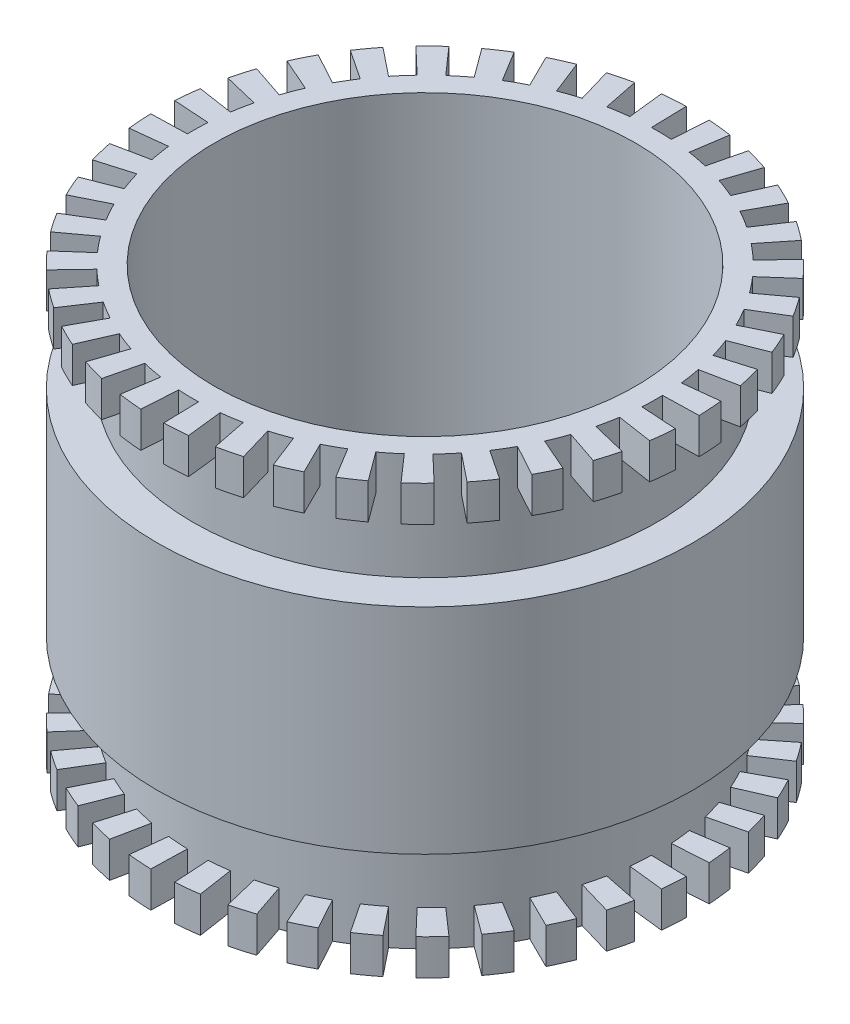
from build123d import *

# Parameters (mm, degrees)
SKETCH1_R           = 37.5
SKETCH1_R_2         = 29.5
BOSS_EXTRUDE1_DEPTH = 60
CUT_EXTRUDE1_DEPTH  = 5
SKETCH3_R           = 37.5
SKETCH3_R_2         = 32.5
CUT_EXTRUDE2_DEPTH  = 10
CUT_EXTRUDE3_DEPTH  = 5
SKETCH5_R           = 37.5
SKETCH5_R_2         = 32.5
CUT_EXTRUDE4_DEPTH  = 10


with BuildPart() as part:
    # Sketch1 → Boss-Extrude1 (new body)
    with BuildSketch(Plane(origin=(0, 0, 0), x_dir=(1, 0, 0), z_dir=(0, 1, 0))):
        Circle(SKETCH1_R)
        Circle(SKETCH1_R_2, mode=Mode.SUBTRACT)
    extrude(amount=BOSS_EXTRUDE1_DEPTH)

    # Sketch2 → Cut-Extrude1 (cut)
    with BuildSketch(Plane.XZ):
        with BuildLine():
            Line((-0.781337231, 32.490606521), (-0.901542959, 37.489161371))
            ThreePointArc((-0.901542959, 37.489161371), (0.734569362, 37.492804748), (2.369283389, 37.42507844))
            Line((2.369283389, 37.42507844), (2.053378937, 32.435067981))
            ThreePointArc((2.053378937, 32.435067981), (0.636626781, 32.493764115), (-0.781337231, 32.490606521))
        make_face()
        with BuildLine():
            Line((4.872467651, 32.132678989), (5.622078059, 37.076168064))
            ThreePointArc((5.622078059, 37.076168064), (7.233966823, 36.795648167), (8.83208532, 36.445085662))
            Line((8.83208532, 36.445085662), (7.654473944, 31.585740907))
            ThreePointArc((7.654473944, 31.585740907), (6.269437913, 31.889561744), (4.872467651, 32.132678989))
        make_face()
        with BuildLine():
            Line((10.378225069, 30.798416265), (11.97487508, 35.536634152))
            ThreePointArc((11.97487508, 35.536634152), (13.513563863, 34.980474435), (15.026528809, 34.357727398))
            Line((15.026528809, 34.357727398), (13.022991634, 29.776697078))
            ThreePointArc((13.022991634, 29.776697078), (11.711755348, 30.316411177), (10.378225069, 30.798416265))
        make_face()
        with BuildLine():
            Line((15.56864537, 28.528359247), (17.963821581, 32.917337593))
            ThreePointArc((17.963821581, 32.917337593), (19.382558102, 32.10243669), (20.764398823, 31.226426973))
            Line((20.764398823, 31.226426973), (17.995812313, 27.062903377))
            ThreePointArc((17.995812313, 27.062903377), (16.798217022, 27.822111798), (15.56864537, 28.528359247))
        make_face()
        with BuildLine():
            Line((20.286020259, 25.39148247), (23.406946453, 29.297864389))
            ThreePointArc((23.406946453, 29.297864389), (24.662623122, 28.24898265), (25.871353087, 27.146327366))
            Line((25.871353087, 27.146327366), (22.421839342, 23.526817051))
            ThreePointArc((22.421839342, 23.526817051), (21.374273373, 24.48245163), (20.286020259, 25.39148247))
        make_face()
        with BuildLine():
            Line((24.387014688, 21.483098347), (28.138863102, 24.788190401))
            ThreePointArc((28.138863102, 24.788190401), (29.193326818, 23.537197566), (30.192219378, 22.241400339))
            Line((30.192219378, 22.241400339), (26.166590128, 19.275880293))
            ThreePointArc((26.166590128, 19.275880293), (25.300883243, 20.398904557), (24.387014688, 21.483098347))
        make_face()
        with BuildLine():
            Line((27.747022016, 16.921961152), (32.015794634, 19.52533979))
            ThreePointArc((32.015794634, 19.52533979), (32.837006052, 18.110246645), (33.595710362, 16.660679617))
            Line((33.595710362, 16.660679617), (29.116282314, 14.439255668))
            ThreePointArc((29.116282314, 14.439255668), (28.458738578, 15.695547093), (27.747022016, 16.921961152))
        make_face()
        with BuildLine():
            Line((30.263950121, 11.846658729), (34.919942448, 13.669221611))
            ThreePointArc((34.919942448, 13.669221611), (35.482949473, 12.133025044), (35.978412686, 10.573732575))
            Line((35.978412686, 10.573732575), (31.181290995, 9.163901565))
            ThreePointArc((31.181290995, 9.163901565), (30.751889543, 10.515288372), (30.263950121, 11.846658729))
        make_face()
        with BuildLine():
            Line((31.861323416, 6.411401577), (36.76306548, 7.39777105))
            ThreePointArc((36.76306548, 7.39777105), (37.050761429, 5.787147617), (37.267929147, 4.16550802))
            Line((37.267929147, 4.16550802), (32.298871928, 3.610106951))
            ThreePointArc((32.298871928, 3.610106951), (32.110659905, 5.015527935), (31.861323416, 6.411401577))
        make_face()
        with BuildLine():
            Line((32.490606521, 0.781337231), (37.489161371, 0.901542959))
            ThreePointArc((37.489161371, 0.901542959), (37.492804748, -0.734569362), (37.42507844, -2.369283389))
            Line((37.42507844, -2.369283389), (32.435067981, -2.053378937))
            ThreePointArc((32.435067981, -2.053378937), (32.493764115, -0.636626781), (32.490606521, 0.781337231))
        make_face()
        with BuildLine():
            Line((32.132678989, -4.872467651), (37.076168064, -5.622078059))
            ThreePointArc((37.076168064, -5.622078059), (36.795648167, -7.233966823), (36.445085662, -8.83208532))
            Line((36.445085662, -8.83208532), (31.585740907, -7.654473944))
            ThreePointArc((31.585740907, -7.654473944), (31.889561744, -6.269437913), (32.132678989, -4.872467651))
        make_face()
        with BuildLine():
            Line((30.798416265, -10.378225069), (35.536634152, -11.97487508))
            ThreePointArc((35.536634152, -11.97487508), (34.980474435, -13.513563863), (34.357727398, -15.026528809))
            Line((34.357727398, -15.026528809), (29.776697078, -13.022991634))
            ThreePointArc((29.776697078, -13.022991634), (30.316411177, -11.711755348), (30.798416265, -10.378225069))
        make_face()
        with BuildLine():
            Line((28.528359247, -15.56864537), (32.917337593, -17.963821581))
            ThreePointArc((32.917337593, -17.963821581), (32.10243669, -19.382558102), (31.226426973, -20.764398823))
            Line((31.226426973, -20.764398823), (27.062903377, -17.995812313))
            ThreePointArc((27.062903377, -17.995812313), (27.822111798, -16.798217022), (28.528359247, -15.56864537))
        make_face()
        with BuildLine():
            Line((25.39148247, -20.286020259), (29.297864389, -23.406946453))
            ThreePointArc((29.297864389, -23.406946453), (28.24898265, -24.662623122), (27.146327366, -25.871353087))
            Line((27.146327366, -25.871353087), (23.526817051, -22.421839342))
            ThreePointArc((23.526817051, -22.421839342), (24.48245163, -21.374273373), (25.39148247, -20.286020259))
        make_face()
        with BuildLine():
            Line((21.483098347, -24.387014688), (24.788190401, -28.138863102))
            ThreePointArc((24.788190401, -28.138863102), (23.537197566, -29.193326818), (22.241400339, -30.192219378))
            Line((22.241400339, -30.192219378), (19.275880293, -26.166590128))
            ThreePointArc((19.275880293, -26.166590128), (20.398904557, -25.300883243), (21.483098347, -24.387014688))
        make_face()
        with BuildLine():
            Line((16.921961152, -27.747022016), (19.52533979, -32.015794634))
            ThreePointArc((19.52533979, -32.015794634), (18.110246645, -32.837006052), (16.660679617, -33.595710362))
            Line((16.660679617, -33.595710362), (14.439255668, -29.116282314))
            ThreePointArc((14.439255668, -29.116282314), (15.695547093, -28.458738578), (16.921961152, -27.747022016))
        make_face()
        with BuildLine():
            Line((11.846658729, -30.263950121), (13.669221611, -34.919942448))
            ThreePointArc((13.669221611, -34.919942448), (12.133025044, -35.482949473), (10.573732575, -35.978412686))
            Line((10.573732575, -35.978412686), (9.163901565, -31.181290995))
            ThreePointArc((9.163901565, -31.181290995), (10.515288372, -30.751889543), (11.846658729, -30.263950121))
        make_face()
        with BuildLine():
            Line((6.411401577, -31.861323416), (7.39777105, -36.76306548))
            ThreePointArc((7.39777105, -36.76306548), (5.787147617, -37.050761429), (4.16550802, -37.267929147))
            Line((4.16550802, -37.267929147), (3.610106951, -32.298871928))
            ThreePointArc((3.610106951, -32.298871928), (5.015527935, -32.110659905), (6.411401577, -31.861323416))
        make_face()
        with BuildLine():
            Line((0.781337231, -32.490606521), (0.901542959, -37.489161371))
            ThreePointArc((0.901542959, -37.489161371), (-0.734569362, -37.492804748), (-2.369283389, -37.42507844))
            Line((-2.369283389, -37.42507844), (-2.053378937, -32.435067981))
            ThreePointArc((-2.053378937, -32.435067981), (-0.636626781, -32.493764115), (0.781337231, -32.490606521))
        make_face()
        with BuildLine():
            Line((-4.872467651, -32.132678989), (-5.622078059, -37.076168064))
            ThreePointArc((-5.622078059, -37.076168064), (-7.233966823, -36.795648167), (-8.83208532, -36.445085662))
            Line((-8.83208532, -36.445085662), (-7.654473944, -31.585740907))
            ThreePointArc((-7.654473944, -31.585740907), (-6.269437913, -31.889561744), (-4.872467651, -32.132678989))
        make_face()
        with BuildLine():
            Line((-10.378225069, -30.798416265), (-11.97487508, -35.536634152))
            ThreePointArc((-11.97487508, -35.536634152), (-13.513563863, -34.980474435), (-15.026528809, -34.357727398))
            Line((-15.026528809, -34.357727398), (-13.022991634, -29.776697078))
            ThreePointArc((-13.022991634, -29.776697078), (-11.711755348, -30.316411177), (-10.378225069, -30.798416265))
        make_face()
        with BuildLine():
            Line((-15.56864537, -28.528359247), (-17.963821581, -32.917337593))
            ThreePointArc((-17.963821581, -32.917337593), (-19.382558102, -32.10243669), (-20.764398823, -31.226426973))
            Line((-20.764398823, -31.226426973), (-17.995812313, -27.062903377))
            ThreePointArc((-17.995812313, -27.062903377), (-16.798217022, -27.822111798), (-15.56864537, -28.528359247))
        make_face()
        with BuildLine():
            Line((-20.286020259, -25.39148247), (-23.406946453, -29.297864389))
            ThreePointArc((-23.406946453, -29.297864389), (-24.662623122, -28.24898265), (-25.871353087, -27.146327366))
            Line((-25.871353087, -27.146327366), (-22.421839342, -23.526817051))
            ThreePointArc((-22.421839342, -23.526817051), (-21.374273373, -24.48245163), (-20.286020259, -25.39148247))
        make_face()
        with BuildLine():
            Line((-24.387014688, -21.483098347), (-28.138863102, -24.788190401))
            ThreePointArc((-28.138863102, -24.788190401), (-29.193326818, -23.537197566), (-30.192219378, -22.241400339))
            Line((-30.192219378, -22.241400339), (-26.166590128, -19.275880293))
            ThreePointArc((-26.166590128, -19.275880293), (-25.300883243, -20.398904557), (-24.387014688, -21.483098347))
        make_face()
        with BuildLine():
            Line((-27.747022016, -16.921961152), (-32.015794634, -19.52533979))
            ThreePointArc((-32.015794634, -19.52533979), (-32.837006052, -18.110246645), (-33.595710362, -16.660679617))
            Line((-33.595710362, -16.660679617), (-29.116282314, -14.439255668))
            ThreePointArc((-29.116282314, -14.439255668), (-28.458738578, -15.695547093), (-27.747022016, -16.921961152))
        make_face()
        with BuildLine():
            Line((-30.263950121, -11.846658729), (-34.919942448, -13.669221611))
            ThreePointArc((-34.919942448, -13.669221611), (-35.482949473, -12.133025044), (-35.978412686, -10.573732575))
            Line((-35.978412686, -10.573732575), (-31.181290995, -9.163901565))
            ThreePointArc((-31.181290995, -9.163901565), (-30.751889543, -10.515288372), (-30.263950121, -11.846658729))
        make_face()
        with BuildLine():
            Line((-31.861323416, -6.411401577), (-36.76306548, -7.39777105))
            ThreePointArc((-36.76306548, -7.39777105), (-37.050761429, -5.787147617), (-37.267929147, -4.16550802))
            Line((-37.267929147, -4.16550802), (-32.298871928, -3.610106951))
            ThreePointArc((-32.298871928, -3.610106951), (-32.110659905, -5.015527935), (-31.861323416, -6.411401577))
        make_face()
        with BuildLine():
            Line((-32.490606521, -0.781337231), (-37.489161371, -0.901542959))
            ThreePointArc((-37.489161371, -0.901542959), (-37.492804748, 0.734569362), (-37.42507844, 2.369283389))
            Line((-37.42507844, 2.369283389), (-32.435067981, 2.053378937))
            ThreePointArc((-32.435067981, 2.053378937), (-32.493764115, 0.636626781), (-32.490606521, -0.781337231))
        make_face()
        with BuildLine():
            Line((-32.132678989, 4.872467651), (-37.076168064, 5.622078059))
            ThreePointArc((-37.076168064, 5.622078059), (-36.795648167, 7.233966823), (-36.445085662, 8.83208532))
            Line((-36.445085662, 8.83208532), (-31.585740907, 7.654473944))
            ThreePointArc((-31.585740907, 7.654473944), (-31.889561744, 6.269437913), (-32.132678989, 4.872467651))
        make_face()
        with BuildLine():
            Line((-30.798416265, 10.378225069), (-35.536634152, 11.97487508))
            ThreePointArc((-35.536634152, 11.97487508), (-34.980474435, 13.513563863), (-34.357727398, 15.026528809))
            Line((-34.357727398, 15.026528809), (-29.776697078, 13.022991634))
            ThreePointArc((-29.776697078, 13.022991634), (-30.316411177, 11.711755348), (-30.798416265, 10.378225069))
        make_face()
        with BuildLine():
            Line((-28.528359247, 15.56864537), (-32.917337593, 17.963821581))
            ThreePointArc((-32.917337593, 17.963821581), (-32.10243669, 19.382558102), (-31.226426973, 20.764398823))
            Line((-31.226426973, 20.764398823), (-27.062903377, 17.995812313))
            ThreePointArc((-27.062903377, 17.995812313), (-27.822111798, 16.798217022), (-28.528359247, 15.56864537))
        make_face()
        with BuildLine():
            Line((-25.39148247, 20.286020259), (-29.297864389, 23.406946453))
            ThreePointArc((-29.297864389, 23.406946453), (-28.24898265, 24.662623122), (-27.146327366, 25.871353087))
            Line((-27.146327366, 25.871353087), (-23.526817051, 22.421839342))
            ThreePointArc((-23.526817051, 22.421839342), (-24.48245163, 21.374273373), (-25.39148247, 20.286020259))
        make_face()
        with BuildLine():
            Line((-21.483098347, 24.387014688), (-24.788190401, 28.138863102))
            ThreePointArc((-24.788190401, 28.138863102), (-23.537197566, 29.193326818), (-22.241400339, 30.192219378))
            Line((-22.241400339, 30.192219378), (-19.275880293, 26.166590128))
            ThreePointArc((-19.275880293, 26.166590128), (-20.398904557, 25.300883243), (-21.483098347, 24.387014688))
        make_face()
        with BuildLine():
            Line((-16.921961152, 27.747022016), (-19.52533979, 32.015794634))
            ThreePointArc((-19.52533979, 32.015794634), (-18.110246645, 32.837006052), (-16.660679617, 33.595710362))
            Line((-16.660679617, 33.595710362), (-14.439255668, 29.116282314))
            ThreePointArc((-14.439255668, 29.116282314), (-15.695547093, 28.458738578), (-16.921961152, 27.747022016))
        make_face()
        with BuildLine():
            Line((-11.846658729, 30.263950121), (-13.669221611, 34.919942448))
            ThreePointArc((-13.669221611, 34.919942448), (-12.133025044, 35.482949473), (-10.573732575, 35.978412686))
            Line((-10.573732575, 35.978412686), (-9.163901565, 31.181290995))
            ThreePointArc((-9.163901565, 31.181290995), (-10.515288372, 30.751889543), (-11.846658729, 30.263950121))
        make_face()
        with BuildLine():
            Line((-6.411401577, 31.861323416), (-7.39777105, 36.76306548))
            ThreePointArc((-7.39777105, 36.76306548), (-5.787147617, 37.050761429), (-4.16550802, 37.267929147))
            Line((-4.16550802, 37.267929147), (-3.610106951, 32.298871928))
            ThreePointArc((-3.610106951, 32.298871928), (-5.015527935, 32.110659905), (-6.411401577, 31.861323416))
        make_face()
    extrude(amount=-CUT_EXTRUDE1_DEPTH, mode=Mode.SUBTRACT)

    # Sketch3 → Cut-Extrude2 (cut)
    with BuildSketch(Plane.XZ.offset(-5)):
        Circle(SKETCH3_R)
        Circle(SKETCH3_R_2, mode=Mode.SUBTRACT)
    extrude(amount=-CUT_EXTRUDE2_DEPTH, mode=Mode.SUBTRACT)

    # Sketch4 → Cut-Extrude3 (cut)
    with BuildSketch(Plane(origin=(0, 60, 0), x_dir=(1, 0, 0), z_dir=(0, 1, 0))):
        with BuildLine():
            Line((-0.781337231, 32.490606521), (-0.901542959, 37.489161371))
            ThreePointArc((-0.901542959, 37.489161371), (0.734569362, 37.492804748), (2.369283389, 37.42507844))
            Line((2.369283389, 37.42507844), (2.053378937, 32.435067981))
            ThreePointArc((2.053378937, 32.435067981), (0.636626781, 32.493764115), (-0.781337231, 32.490606521))
        make_face()
        with BuildLine():
            Line((4.872467651, 32.132678989), (5.622078059, 37.076168064))
            ThreePointArc((5.622078059, 37.076168064), (7.233966823, 36.795648167), (8.83208532, 36.445085662))
            Line((8.83208532, 36.445085662), (7.654473944, 31.585740907))
            ThreePointArc((7.654473944, 31.585740907), (6.269437913, 31.889561744), (4.872467651, 32.132678989))
        make_face()
        with BuildLine():
            Line((10.378225069, 30.798416265), (11.97487508, 35.536634152))
            ThreePointArc((11.97487508, 35.536634152), (13.513563863, 34.980474435), (15.026528809, 34.357727398))
            Line((15.026528809, 34.357727398), (13.022991634, 29.776697078))
            ThreePointArc((13.022991634, 29.776697078), (11.711755348, 30.316411177), (10.378225069, 30.798416265))
        make_face()
        with BuildLine():
            Line((15.56864537, 28.528359247), (17.963821581, 32.917337593))
            ThreePointArc((17.963821581, 32.917337593), (19.382558102, 32.10243669), (20.764398823, 31.226426973))
            Line((20.764398823, 31.226426973), (17.995812313, 27.062903377))
            ThreePointArc((17.995812313, 27.062903377), (16.798217022, 27.822111798), (15.56864537, 28.528359247))
        make_face()
        with BuildLine():
            Line((20.286020259, 25.39148247), (23.406946453, 29.297864389))
            ThreePointArc((23.406946453, 29.297864389), (24.662623122, 28.24898265), (25.871353087, 27.146327366))
            Line((25.871353087, 27.146327366), (22.421839342, 23.526817051))
            ThreePointArc((22.421839342, 23.526817051), (21.374273373, 24.48245163), (20.286020259, 25.39148247))
        make_face()
        with BuildLine():
            Line((24.387014688, 21.483098347), (28.138863102, 24.788190401))
            ThreePointArc((28.138863102, 24.788190401), (29.193326818, 23.537197566), (30.192219378, 22.241400339))
            Line((30.192219378, 22.241400339), (26.166590128, 19.275880293))
            ThreePointArc((26.166590128, 19.275880293), (25.300883243, 20.398904557), (24.387014688, 21.483098347))
        make_face()
        with BuildLine():
            Line((27.747022016, 16.921961152), (32.015794634, 19.52533979))
            ThreePointArc((32.015794634, 19.52533979), (32.837006052, 18.110246645), (33.595710362, 16.660679617))
            Line((33.595710362, 16.660679617), (29.116282314, 14.439255668))
            ThreePointArc((29.116282314, 14.439255668), (28.458738578, 15.695547093), (27.747022016, 16.921961152))
        make_face()
        with BuildLine():
            Line((30.263950121, 11.846658729), (34.919942448, 13.669221611))
            ThreePointArc((34.919942448, 13.669221611), (35.482949473, 12.133025044), (35.978412686, 10.573732575))
            Line((35.978412686, 10.573732575), (31.181290995, 9.163901565))
            ThreePointArc((31.181290995, 9.163901565), (30.751889543, 10.515288372), (30.263950121, 11.846658729))
        make_face()
        with BuildLine():
            Line((31.861323416, 6.411401577), (36.76306548, 7.39777105))
            ThreePointArc((36.76306548, 7.39777105), (37.050761429, 5.787147617), (37.267929147, 4.16550802))
            Line((37.267929147, 4.16550802), (32.298871928, 3.610106951))
            ThreePointArc((32.298871928, 3.610106951), (32.110659905, 5.015527935), (31.861323416, 6.411401577))
        make_face()
        with BuildLine():
            Line((32.490606521, 0.781337231), (37.489161371, 0.901542959))
            ThreePointArc((37.489161371, 0.901542959), (37.492804748, -0.734569362), (37.42507844, -2.369283389))
            Line((37.42507844, -2.369283389), (32.435067981, -2.053378937))
            ThreePointArc((32.435067981, -2.053378937), (32.493764115, -0.636626781), (32.490606521, 0.781337231))
        make_face()
        with BuildLine():
            Line((32.132678989, -4.872467651), (37.076168064, -5.622078059))
            ThreePointArc((37.076168064, -5.622078059), (36.795648167, -7.233966823), (36.445085662, -8.83208532))
            Line((36.445085662, -8.83208532), (31.585740907, -7.654473944))
            ThreePointArc((31.585740907, -7.654473944), (31.889561744, -6.269437913), (32.132678989, -4.872467651))
        make_face()
        with BuildLine():
            Line((30.798416265, -10.378225069), (35.536634152, -11.97487508))
            ThreePointArc((35.536634152, -11.97487508), (34.980474435, -13.513563863), (34.357727398, -15.026528809))
            Line((34.357727398, -15.026528809), (29.776697078, -13.022991634))
            ThreePointArc((29.776697078, -13.022991634), (30.316411177, -11.711755348), (30.798416265, -10.378225069))
        make_face()
        with BuildLine():
            Line((28.528359247, -15.56864537), (32.917337593, -17.963821581))
            ThreePointArc((32.917337593, -17.963821581), (32.10243669, -19.382558102), (31.226426973, -20.764398823))
            Line((31.226426973, -20.764398823), (27.062903377, -17.995812313))
            ThreePointArc((27.062903377, -17.995812313), (27.822111798, -16.798217022), (28.528359247, -15.56864537))
        make_face()
        with BuildLine():
            Line((25.39148247, -20.286020259), (29.297864389, -23.406946453))
            ThreePointArc((29.297864389, -23.406946453), (28.24898265, -24.662623122), (27.146327366, -25.871353087))
            Line((27.146327366, -25.871353087), (23.526817051, -22.421839342))
            ThreePointArc((23.526817051, -22.421839342), (24.48245163, -21.374273373), (25.39148247, -20.286020259))
        make_face()
        with BuildLine():
            Line((21.483098347, -24.387014688), (24.788190401, -28.138863102))
            ThreePointArc((24.788190401, -28.138863102), (23.537197566, -29.193326818), (22.241400339, -30.192219378))
            Line((22.241400339, -30.192219378), (19.275880293, -26.166590128))
            ThreePointArc((19.275880293, -26.166590128), (20.398904557, -25.300883243), (21.483098347, -24.387014688))
        make_face()
        with BuildLine():
            Line((16.921961152, -27.747022016), (19.52533979, -32.015794634))
            ThreePointArc((19.52533979, -32.015794634), (18.110246645, -32.837006052), (16.660679617, -33.595710362))
            Line((16.660679617, -33.595710362), (14.439255668, -29.116282314))
            ThreePointArc((14.439255668, -29.116282314), (15.695547093, -28.458738578), (16.921961152, -27.747022016))
        make_face()
        with BuildLine():
            Line((11.846658729, -30.263950121), (13.669221611, -34.919942448))
            ThreePointArc((13.669221611, -34.919942448), (12.133025044, -35.482949473), (10.573732575, -35.978412686))
            Line((10.573732575, -35.978412686), (9.163901565, -31.181290995))
            ThreePointArc((9.163901565, -31.181290995), (10.515288372, -30.751889543), (11.846658729, -30.263950121))
        make_face()
        with BuildLine():
            Line((6.411401577, -31.861323416), (7.39777105, -36.76306548))
            ThreePointArc((7.39777105, -36.76306548), (5.787147617, -37.050761429), (4.16550802, -37.267929147))
            Line((4.16550802, -37.267929147), (3.610106951, -32.298871928))
            ThreePointArc((3.610106951, -32.298871928), (5.015527935, -32.110659905), (6.411401577, -31.861323416))
        make_face()
        with BuildLine():
            Line((0.781337231, -32.490606521), (0.901542959, -37.489161371))
            ThreePointArc((0.901542959, -37.489161371), (-0.734569362, -37.492804748), (-2.369283389, -37.42507844))
            Line((-2.369283389, -37.42507844), (-2.053378937, -32.435067981))
            ThreePointArc((-2.053378937, -32.435067981), (-0.636626781, -32.493764115), (0.781337231, -32.490606521))
        make_face()
        with BuildLine():
            Line((-4.872467651, -32.132678989), (-5.622078059, -37.076168064))
            ThreePointArc((-5.622078059, -37.076168064), (-7.233966823, -36.795648167), (-8.83208532, -36.445085662))
            Line((-8.83208532, -36.445085662), (-7.654473944, -31.585740907))
            ThreePointArc((-7.654473944, -31.585740907), (-6.269437913, -31.889561744), (-4.872467651, -32.132678989))
        make_face()
        with BuildLine():
            Line((-10.378225069, -30.798416265), (-11.97487508, -35.536634152))
            ThreePointArc((-11.97487508, -35.536634152), (-13.513563863, -34.980474435), (-15.026528809, -34.357727398))
            Line((-15.026528809, -34.357727398), (-13.022991634, -29.776697078))
            ThreePointArc((-13.022991634, -29.776697078), (-11.711755348, -30.316411177), (-10.378225069, -30.798416265))
        make_face()
        with BuildLine():
            Line((-15.56864537, -28.528359247), (-17.963821581, -32.917337593))
            ThreePointArc((-17.963821581, -32.917337593), (-19.382558102, -32.10243669), (-20.764398823, -31.226426973))
            Line((-20.764398823, -31.226426973), (-17.995812313, -27.062903377))
            ThreePointArc((-17.995812313, -27.062903377), (-16.798217022, -27.822111798), (-15.56864537, -28.528359247))
        make_face()
        with BuildLine():
            Line((-20.286020259, -25.39148247), (-23.406946453, -29.297864389))
            ThreePointArc((-23.406946453, -29.297864389), (-24.662623122, -28.24898265), (-25.871353087, -27.146327366))
            Line((-25.871353087, -27.146327366), (-22.421839342, -23.526817051))
            ThreePointArc((-22.421839342, -23.526817051), (-21.374273373, -24.48245163), (-20.286020259, -25.39148247))
        make_face()
        with BuildLine():
            Line((-24.387014688, -21.483098347), (-28.138863102, -24.788190401))
            ThreePointArc((-28.138863102, -24.788190401), (-29.193326818, -23.537197566), (-30.192219378, -22.241400339))
            Line((-30.192219378, -22.241400339), (-26.166590128, -19.275880293))
            ThreePointArc((-26.166590128, -19.275880293), (-25.300883243, -20.398904557), (-24.387014688, -21.483098347))
        make_face()
        with BuildLine():
            Line((-27.747022016, -16.921961152), (-32.015794634, -19.52533979))
            ThreePointArc((-32.015794634, -19.52533979), (-32.837006052, -18.110246645), (-33.595710362, -16.660679617))
            Line((-33.595710362, -16.660679617), (-29.116282314, -14.439255668))
            ThreePointArc((-29.116282314, -14.439255668), (-28.458738578, -15.695547093), (-27.747022016, -16.921961152))
        make_face()
        with BuildLine():
            Line((-30.263950121, -11.846658729), (-34.919942448, -13.669221611))
            ThreePointArc((-34.919942448, -13.669221611), (-35.482949473, -12.133025044), (-35.978412686, -10.573732575))
            Line((-35.978412686, -10.573732575), (-31.181290995, -9.163901565))
            ThreePointArc((-31.181290995, -9.163901565), (-30.751889543, -10.515288372), (-30.263950121, -11.846658729))
        make_face()
        with BuildLine():
            Line((-31.861323416, -6.411401577), (-36.76306548, -7.39777105))
            ThreePointArc((-36.76306548, -7.39777105), (-37.050761429, -5.787147617), (-37.267929147, -4.16550802))
            Line((-37.267929147, -4.16550802), (-32.298871928, -3.610106951))
            ThreePointArc((-32.298871928, -3.610106951), (-32.110659905, -5.015527935), (-31.861323416, -6.411401577))
        make_face()
        with BuildLine():
            Line((-32.490606521, -0.781337231), (-37.489161371, -0.901542959))
            ThreePointArc((-37.489161371, -0.901542959), (-37.492804748, 0.734569362), (-37.42507844, 2.369283389))
            Line((-37.42507844, 2.369283389), (-32.435067981, 2.053378937))
            ThreePointArc((-32.435067981, 2.053378937), (-32.493764115, 0.636626781), (-32.490606521, -0.781337231))
        make_face()
        with BuildLine():
            Line((-32.132678989, 4.872467651), (-37.076168064, 5.622078059))
            ThreePointArc((-37.076168064, 5.622078059), (-36.795648167, 7.233966823), (-36.445085662, 8.83208532))
            Line((-36.445085662, 8.83208532), (-31.585740907, 7.654473944))
            ThreePointArc((-31.585740907, 7.654473944), (-31.889561744, 6.269437913), (-32.132678989, 4.872467651))
        make_face()
        with BuildLine():
            Line((-30.798416265, 10.378225069), (-35.536634152, 11.97487508))
            ThreePointArc((-35.536634152, 11.97487508), (-34.980474435, 13.513563863), (-34.357727398, 15.026528809))
            Line((-34.357727398, 15.026528809), (-29.776697078, 13.022991634))
            ThreePointArc((-29.776697078, 13.022991634), (-30.316411177, 11.711755348), (-30.798416265, 10.378225069))
        make_face()
        with BuildLine():
            Line((-28.528359247, 15.56864537), (-32.917337593, 17.963821581))
            ThreePointArc((-32.917337593, 17.963821581), (-32.10243669, 19.382558102), (-31.226426973, 20.764398823))
            Line((-31.226426973, 20.764398823), (-27.062903377, 17.995812313))
            ThreePointArc((-27.062903377, 17.995812313), (-27.822111798, 16.798217022), (-28.528359247, 15.56864537))
        make_face()
        with BuildLine():
            Line((-25.39148247, 20.286020259), (-29.297864389, 23.406946453))
            ThreePointArc((-29.297864389, 23.406946453), (-28.24898265, 24.662623122), (-27.146327366, 25.871353087))
            Line((-27.146327366, 25.871353087), (-23.526817051, 22.421839342))
            ThreePointArc((-23.526817051, 22.421839342), (-24.48245163, 21.374273373), (-25.39148247, 20.286020259))
        make_face()
        with BuildLine():
            Line((-21.483098347, 24.387014688), (-24.788190401, 28.138863102))
            ThreePointArc((-24.788190401, 28.138863102), (-23.537197566, 29.193326818), (-22.241400339, 30.192219378))
            Line((-22.241400339, 30.192219378), (-19.275880293, 26.166590128))
            ThreePointArc((-19.275880293, 26.166590128), (-20.398904557, 25.300883243), (-21.483098347, 24.387014688))
        make_face()
        with BuildLine():
            Line((-16.921961152, 27.747022016), (-19.52533979, 32.015794634))
            ThreePointArc((-19.52533979, 32.015794634), (-18.110246645, 32.837006052), (-16.660679617, 33.595710362))
            Line((-16.660679617, 33.595710362), (-14.439255668, 29.116282314))
            ThreePointArc((-14.439255668, 29.116282314), (-15.695547093, 28.458738578), (-16.921961152, 27.747022016))
        make_face()
        with BuildLine():
            Line((-11.846658729, 30.263950121), (-13.669221611, 34.919942448))
            ThreePointArc((-13.669221611, 34.919942448), (-12.133025044, 35.482949473), (-10.573732575, 35.978412686))
            Line((-10.573732575, 35.978412686), (-9.163901565, 31.181290995))
            ThreePointArc((-9.163901565, 31.181290995), (-10.515288372, 30.751889543), (-11.846658729, 30.263950121))
        make_face()
        with BuildLine():
            Line((-6.411401577, 31.861323416), (-7.39777105, 36.76306548))
            ThreePointArc((-7.39777105, 36.76306548), (-5.787147617, 37.050761429), (-4.16550802, 37.267929147))
            Line((-4.16550802, 37.267929147), (-3.610106951, 32.298871928))
            ThreePointArc((-3.610106951, 32.298871928), (-5.015527935, 32.110659905), (-6.411401577, 31.861323416))
        make_face()
    extrude(amount=-CUT_EXTRUDE3_DEPTH, mode=Mode.SUBTRACT)

    # Sketch5 → Cut-Extrude4 (cut)
    with BuildSketch(Plane(origin=(0, 55, 0), x_dir=(1, 0, 0), z_dir=(0, 1, 0))):
        Circle(SKETCH5_R)
        Circle(SKETCH5_R_2, mode=Mode.SUBTRACT)
    extrude(amount=-CUT_EXTRUDE4_DEPTH, mode=Mode.SUBTRACT)


solid = part.part
